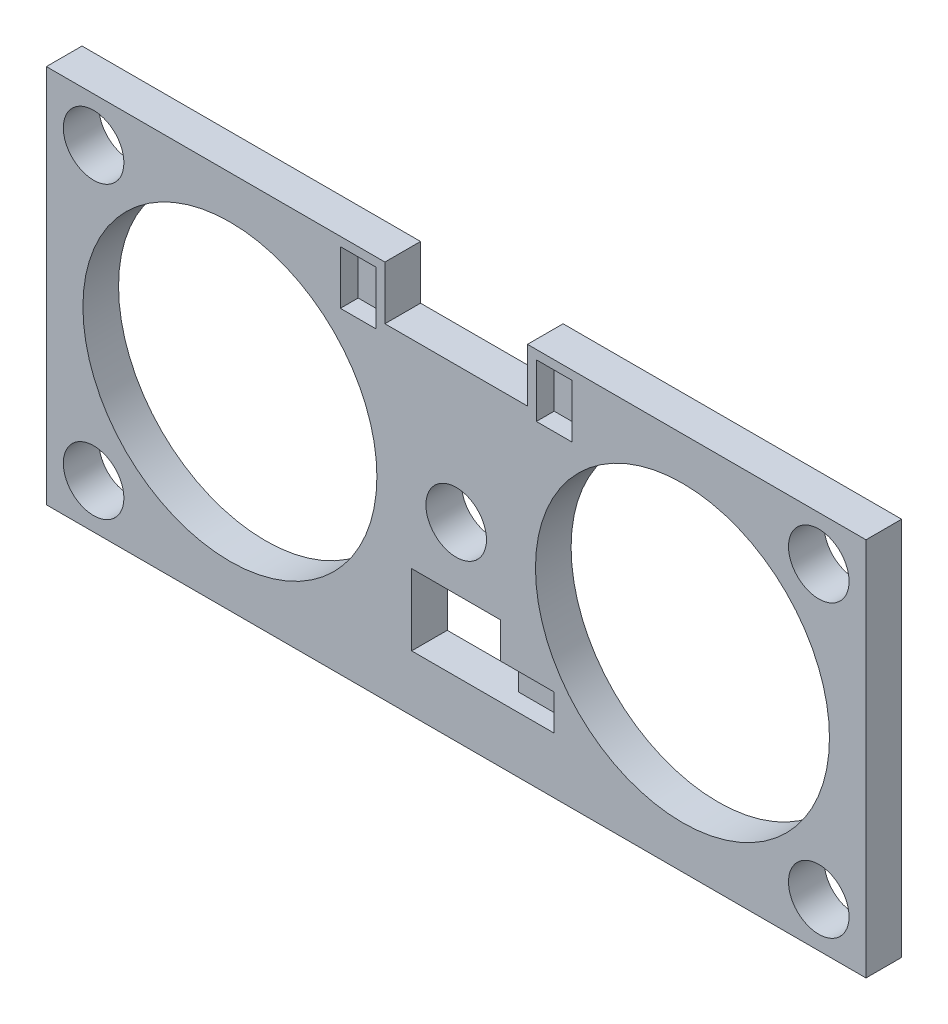
from build123d import *

# Parameters (mm, degrees)
SKETCH_1_W          = 46
SKETCH_1_H          = 21.3
EXTRUDE_1_DEPTH     = 2
SKETCH_2_R          = 8.25
CUT_EXTRUDE_1_DEPTH = 3
SKETCH_3_W          = 8
SKETCH_3_H          = 3
CUT_EXTRUDE_2_DEPTH = 3
SKETCH_4_W          = 5
SKETCH_4_H          = 4
CUT_EXTRUDE_3_DEPTH = 3
SKETCH_5_W          = 3
SKETCH_5_H          = 2
SKETCH_5_W_2        = 2
SKETCH_5_H_2        = 3
CUT_EXTRUDE_4_DEPTH = 1
HOLE_WIZARD_M3_1_D  = 3.4


with BuildPart() as part:
    # 草圖1 → 填料-伸長1 (new body)
    with BuildSketch(Plane.XY):
        Rectangle(SKETCH_1_W, SKETCH_1_H)
    extrude(amount=EXTRUDE_1_DEPTH)

    # 草圖2 → 除料-伸長1 (cut, through all)
    with BuildSketch(Plane.XY.offset(2)):
        with Locations((-12.7, 0)):
            Circle(SKETCH_2_R)
        with Locations((12.7, 0)):
            Circle(SKETCH_2_R)
    extrude(amount=-CUT_EXTRUDE_1_DEPTH, mode=Mode.SUBTRACT)

    # 草圖3 → 除料-伸長2 (cut, through all)
    with BuildSketch(Plane.XY.offset(2)):
        with Locations((0, 9.15)):
            Rectangle(SKETCH_3_W, SKETCH_3_H)
    extrude(amount=-CUT_EXTRUDE_2_DEPTH, mode=Mode.SUBTRACT)

    # 草圖4 → 除料-伸長3 (cut, through all)
    with BuildSketch(Plane.XY.offset(2)):
        with Locations((0, -5.5)):
            Rectangle(SKETCH_4_W, SKETCH_4_H)
    extrude(amount=-CUT_EXTRUDE_3_DEPTH, mode=Mode.SUBTRACT)

    # 草圖5 → 除料-伸長4 (cut)
    with BuildSketch(Plane.XY.offset(2)):
        with Locations((4, -6.5)):
            Rectangle(SKETCH_5_W, SKETCH_5_H)
        with Locations((-5.5, 8.65)):
            Rectangle(SKETCH_5_W_2, SKETCH_5_H_2)
        with Locations((5.5, 8.65)):
            Rectangle(SKETCH_5_W_2, SKETCH_5_H_2)
    extrude(amount=-CUT_EXTRUDE_4_DEPTH, mode=Mode.SUBTRACT)

    # M3 餘隙孔1 (through all)
    with Locations(Plane.XY.offset(2)):
        with Locations((0, 0), (20.35, 8.15), (-20.35, -8.15), (-20.35, 8.15), (20.35, -8.15)):
            Hole(HOLE_WIZARD_M3_1_D / 2)


solid = part.part
